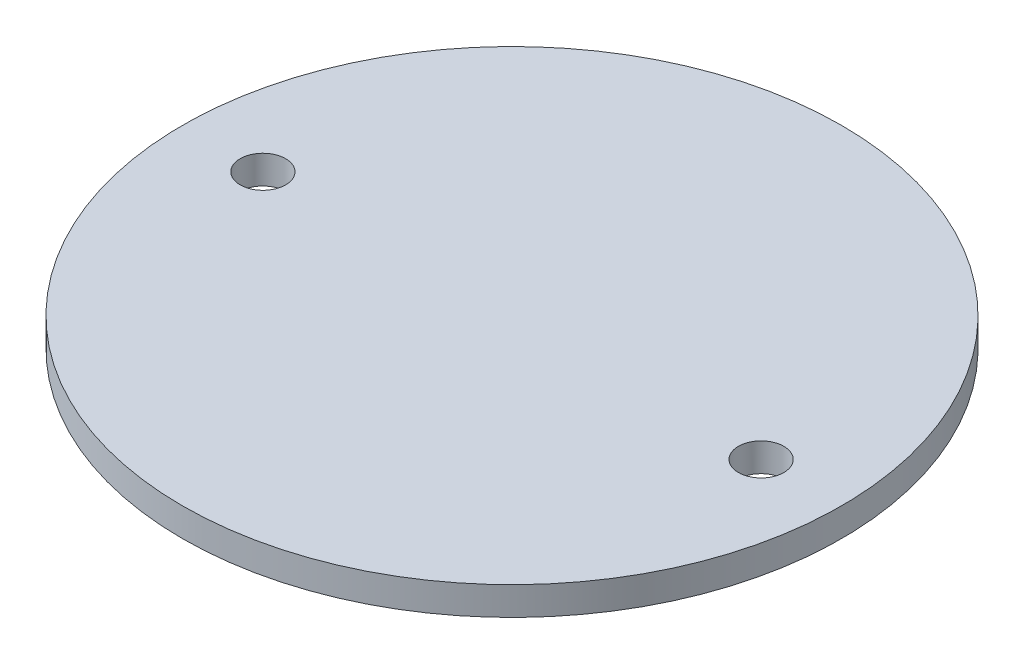
from build123d import *

# Parameters (mm, degrees)
SKETCH1_R               = 73.66
BOSS_EXTRUDE1_DEPTH     = 6.35
SKETCH2_R               = 5.08
CUT_EXTRUDE1_DEPTH      = 7.35
CUT_EXTRUDE1_DEPTH_BACK = 1


with BuildPart() as part:
    # Sketch1 → Boss-Extrude1 (new body)
    with BuildSketch(Plane(origin=(0, 0, 0), x_dir=(1, 0, 0), z_dir=(0, 1, 0))):
        Circle(SKETCH1_R)
    extrude(amount=BOSS_EXTRUDE1_DEPTH)

    # Sketch2 → Cut-Extrude1 (cut, two sides)
    with BuildSketch(Plane(origin=(0, 0, 0), x_dir=(1, 0, 0), z_dir=(0, 1, 0))) as cut_extrude1_sk:
        with Locations((-55.67867444, 0)):
            Circle(SKETCH2_R)
        with Locations((55.67867444, 0)):
            Circle(SKETCH2_R)
    extrude(amount=CUT_EXTRUDE1_DEPTH, mode=Mode.SUBTRACT)
    extrude(cut_extrude1_sk.sketch, amount=-CUT_EXTRUDE1_DEPTH_BACK, mode=Mode.SUBTRACT)


solid = part.part
